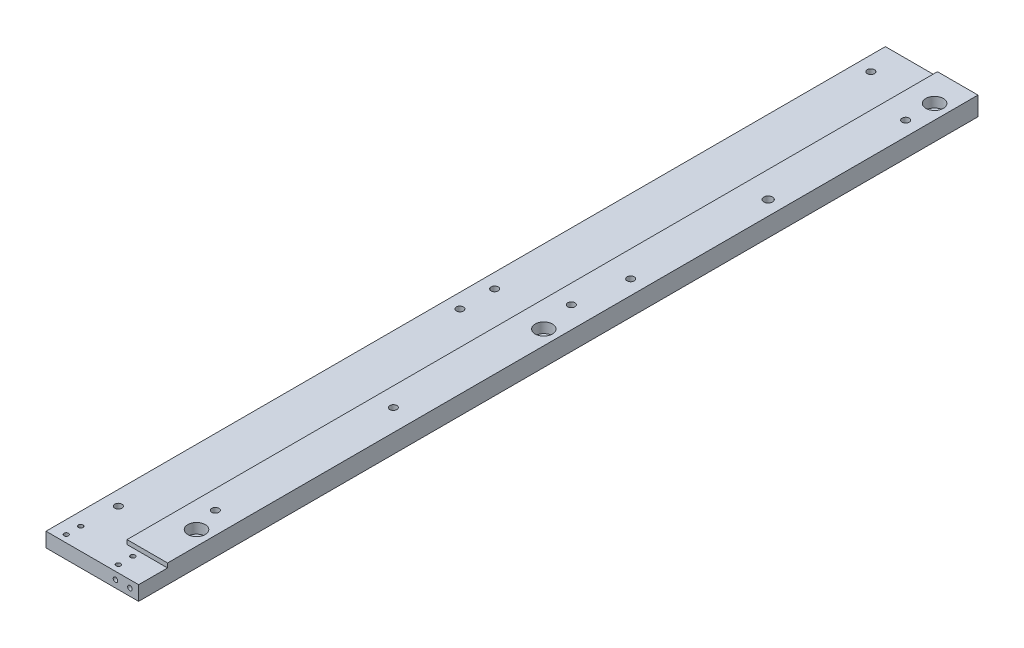
from build123d import *

# Parameters (mm, degrees)
SKETCH1_W           = 32
SKETCH1_H           = 5
BOSS_EXTRUDE1_DEPTH = 290
SKETCH2_W           = 14
SKETCH2_H           = 280
BOSS_EXTRUDE2_DEPTH = 1.5
SKETCH3_R           = 3
CUT_EXTRUDE1_DEPTH  = 3.5
SKETCH4_R           = 1.75
CUT_EXTRUDE2_DEPTH  = 4
SKETCH5_R           = 0.785
CUT_EXTRUDE3_DEPTH  = 6
SKETCH6_R           = 1.23
CUT_EXTRUDE4_DEPTH  = 7.5
LPATTERN1_COUNT     = 2
LPATTERN1_PITCH     = 95
SKETCH7_R           = 1.23
CUT_EXTRUDE5_DEPTH  = 7.5
SKETCH8_R           = 1.23
CUT_EXTRUDE6_DEPTH  = 7.5
LPATTERN2_COUNT     = 3
LPATTERN2_PITCH     = 61.5
SKETCH9_R           = 1.5
CUT_EXTRUDE7_DEPTH  = 7.5
SKETCH10_R          = 0.785
CUT_EXTRUDE8_DEPTH  = 8


with BuildPart() as part:
    # Sketch1 → Boss-Extrude1 (new body)
    with BuildSketch(Plane.XY):
        Rectangle(SKETCH1_W, SKETCH1_H)
    extrude(amount=BOSS_EXTRUDE1_DEPTH)

    # Sketch2 → Boss-Extrude2 (add)
    with BuildSketch(Plane(origin=(0, 2.5, 0), x_dir=(1, 0, 0), z_dir=(0, 1, 0))):
        with Locations((9, -140)):
            Rectangle(SKETCH2_W, SKETCH2_H)
    extrude(amount=BOSS_EXTRUDE2_DEPTH)

    # Sketch3 → Cut-Extrude1 (cut)
    with BuildSketch(Plane(origin=(0, 4, 0), x_dir=(1, 0, 0), z_dir=(0, 1, 0))):
        with Locations((11, -10)):
            Circle(SKETCH3_R)
        with Locations((11, -145)):
            Circle(SKETCH3_R)
        with Locations((11, -265)):
            Circle(SKETCH3_R)
    extrude(amount=-CUT_EXTRUDE1_DEPTH, mode=Mode.SUBTRACT)

    # Sketch4 → Cut-Extrude2 (cut, through all)
    with BuildSketch(Plane(origin=(0, 0.5, 0), x_dir=(1, 0, 0), z_dir=(0, 1, 0))):
        with Locations((11, -10)):
            Circle(SKETCH4_R)
        with Locations((11, -145)):
            Circle(SKETCH4_R)
        with Locations((11, -265)):
            Circle(SKETCH4_R)
    extrude(amount=-CUT_EXTRUDE2_DEPTH, mode=Mode.SUBTRACT)

    # Sketch5 → Cut-Extrude3 (cut, through all)
    with BuildSketch(Plane(origin=(0, 2.5, 0), x_dir=(1, 0, 0), z_dir=(0, 1, 0))):
        with Locations((-11.5, -282.5)):
            Circle(SKETCH5_R)
        with Locations((6.5, -282.5)):
            Circle(SKETCH5_R)
        with Locations((-11.5, -287.5)):
            Circle(SKETCH5_R)
        with Locations((6.5, -287.5)):
            Circle(SKETCH5_R)
    extrude(amount=-CUT_EXTRUDE3_DEPTH, mode=Mode.SUBTRACT)

    # Sketch6 → Cut-Extrude4 (cut, through all)
    with BuildSketch(Plane(origin=(0, 4, 0), x_dir=(1, 0, 0), z_dir=(0, 1, 0))):
        with Locations((11, -20)):
            Circle(SKETCH6_R)
    cut_extrude4 = extrude(amount=-CUT_EXTRUDE4_DEPTH, mode=Mode.SUBTRACT)

    # LPattern1: Cut-Extrude4 ×2
    with Locations(*[(0, 0, i * LPATTERN1_PITCH) for i in range(1, LPATTERN1_COUNT)]):
        add(cut_extrude4, mode=Mode.SUBTRACT)

    # Sketch7 → Cut-Extrude5 (cut, through all)
    with BuildSketch(Plane.XZ.offset(2.5)):
        with Locations((-11, 10)):
            Circle(SKETCH7_R)
        with Locations((-11, 140)):
            Circle(SKETCH7_R)
        with Locations((-11, 152)):
            Circle(SKETCH7_R)
        with Locations((-11, 270)):
            Circle(SKETCH7_R)
    extrude(amount=-CUT_EXTRUDE5_DEPTH, mode=Mode.SUBTRACT)

    # Sketch8 → Cut-Extrude6 (cut, through all)
    with BuildSketch(Plane.XZ.offset(2.5)):
        with Locations((8.5, 133)):
            Circle(SKETCH8_R)
    cut_extrude6 = extrude(amount=-CUT_EXTRUDE6_DEPTH, mode=Mode.SUBTRACT)

    # LPattern2: Cut-Extrude6 ×3
    with Locations(*[(0, 0, i * LPATTERN2_PITCH) for i in range(1, LPATTERN2_COUNT)]):
        add(cut_extrude6, mode=Mode.SUBTRACT)

    # Sketch9 → Cut-Extrude7 (cut, through all)
    with BuildSketch(Plane.XZ.offset(2.5)):
        with Locations((11, 67.5)):
            Circle(SKETCH9_R)
    extrude(amount=-CUT_EXTRUDE7_DEPTH, mode=Mode.SUBTRACT)

    # Sketch10 → Cut-Extrude8 (cut)
    with BuildSketch(Plane.XY.offset(290)):
        with Locations((13, 0)):
            Circle(SKETCH10_R)
        with Locations((8, 0)):
            Circle(SKETCH10_R)
    extrude(amount=-CUT_EXTRUDE8_DEPTH, mode=Mode.SUBTRACT)


solid = part.part
